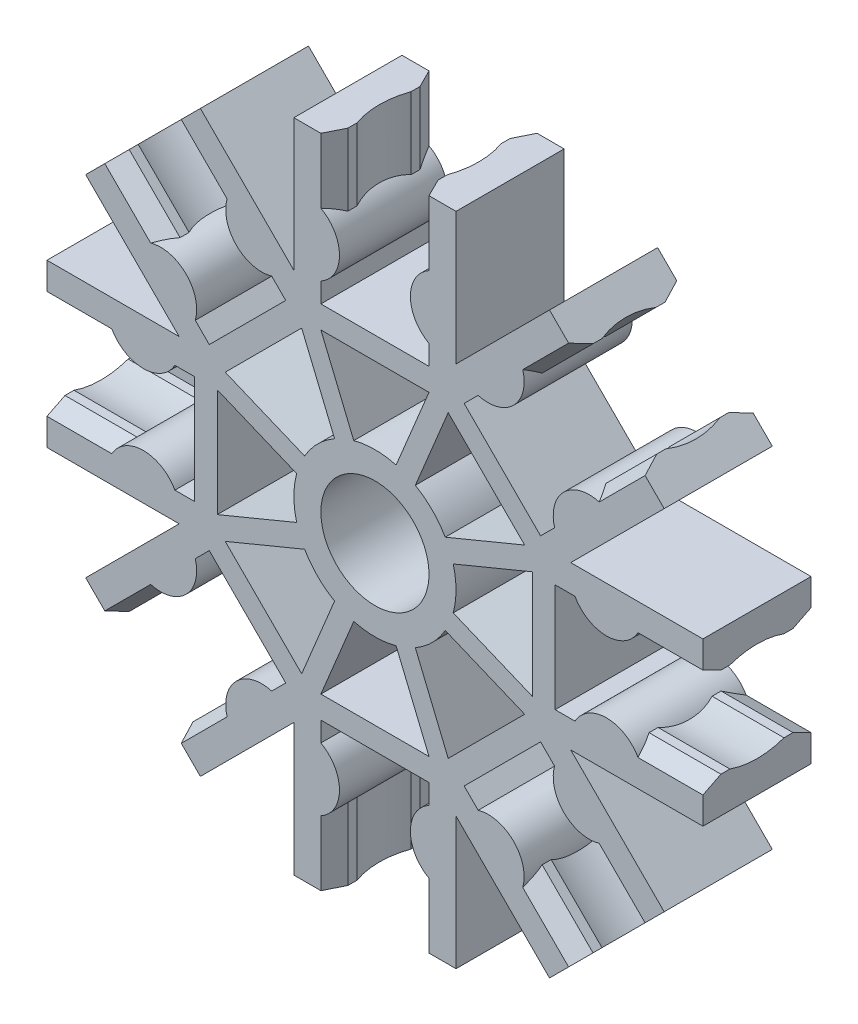
from build123d import *

# Parameters (mm, degrees)
EXTRUDE_1_DEPTH          = 6
EXTRUDE_2_REACH          = 25.907
PATTERN_CIRCULAR_1_COUNT = 8
SKETCH_4_R               = 3
CUT_EXTRUDE_1_DEPTH      = 27.42877236


with BuildPart() as part:
    # 草图1 → 凸台-拉伸1 (new body)
    with BuildSketch(Plane.XY):
        with BuildLine():
            Line((-4.5, 0), (-4.5, -18.2))
            Line((-4.5, -18.2), (-3, -18.2))
            Line((-3, -18.2), (-3, -14.6))
            ThreePointArc((-3, -14.6), (-1.968245837, -12.85), (-3, -11.1))
            Line((-3, -11.1), (-3, -10))
            Line((-3, -10), (3, -10))
            Line((3, -10), (3, -11.1))
            ThreePointArc((3, -11.1), (1.968245837, -12.85), (3, -14.6))
            Line((3, -14.6), (3, -18.2))
            Line((3, -18.2), (4.5, -18.2))
            Line((4.5, -18.2), (4.5, 0))
            ThreePointArc((4.5, 0), (0, 4.5), (-4.5, 0))
        make_face()
    extrude_1 = extrude(amount=EXTRUDE_1_DEPTH)

    # 草图3 → 凸台-拉伸2 (add, up to next)
    with BuildSketch(Plane.XZ.offset(18.2), mode=Mode.PRIVATE) as extrude_2_sk1:
        with BuildLine():
            Line((-3, 6), (-3, 0))
            Line((-3, 0), (-2.5, 1))
            Line((-2.5, 1), (-2.5, 1.5))
            ThreePointArc((-2.5, 1.5), (-2.757359313, 3), (-2.5, 4.5))
            Line((-2.5, 4.5), (-2.5, 5))
            Line((-2.5, 5), (-3, 6))
        make_face()
    extrude_2_tool1 = extrude(extrude_2_sk1.sketch, amount=-EXTRUDE_2_REACH, mode=Mode.PRIVATE) - part.part
    # 草图3 → 凸台-拉伸2 (add, up to next)
    with BuildSketch(Plane.XZ.offset(18.2), mode=Mode.PRIVATE) as extrude_2_sk2:
        with BuildLine():
            Line((3, 0), (2.5, 1))
            Line((2.5, 1), (2.5, 1.5))
            ThreePointArc((2.5, 1.5), (2.757359313, 3), (2.5, 4.5))
            Line((2.5, 4.5), (2.5, 5))
            Line((2.5, 5), (3, 6))
            Line((3, 6), (3, 0))
        make_face()
    extrude_2_tool2 = extrude(extrude_2_sk2.sketch, amount=-EXTRUDE_2_REACH, mode=Mode.PRIVATE) - part.part
    extrude_2_1 = extrude_2_tool1.solids().sort_by_distance((-2.809362, -18.2, 3))[0]
    add(extrude_2_1)
    extrude_2_2 = extrude_2_tool2.solids().sort_by_distance((2.809362, -18.2, 3))[0]
    add(extrude_2_2)
    extrude_2 = extrude_2_1 + extrude_2_2  # 凸台-拉伸2 as one shape, for the pattern or mirror that repeats it

    # 阵列(圆周)1: 凸台-拉伸1, 凸台-拉伸2 ×8 about axis
    pattern_circular_1_axis = Axis((0, 0, 0), (0, 0, 1))
    add([extrude_1.rotate(pattern_circular_1_axis, i * 360 / PATTERN_CIRCULAR_1_COUNT) for i in range(1, PATTERN_CIRCULAR_1_COUNT)])
    add([extrude_2.rotate(pattern_circular_1_axis, i * 360 / PATTERN_CIRCULAR_1_COUNT) for i in range(1, PATTERN_CIRCULAR_1_COUNT)])

    # 草图4 → 切除-拉伸1 (cut, through all)
    with BuildSketch(Plane(origin=(0, 0, 0), x_dir=(-1, 0, 0), z_dir=(0, 0, -1))):
        Circle(SKETCH_4_R)
        with BuildLine():
            Line((-3, -8.75), (3, -8.75))
            Line((3, -8.75), (1.174936357, -4.343906601))
            ThreePointArc((1.174936357, -4.343906601), (0, -4.5), (-1.174936357, -4.343906601))
            Line((-1.174936357, -4.343906601), (-3, -8.75))
        make_face()
        with BuildLine():
            Line((-8.308504679, -4.065863992), (-3.90241128, -2.240800349))
            ThreePointArc((-3.90241128, -2.240800349), (-3.181980515, -3.181980515), (-2.240800349, -3.90241128))
            Line((-2.240800349, -3.90241128), (-4.065863992, -8.308504679))
            Line((-4.065863992, -8.308504679), (-8.308504679, -4.065863992))
        make_face()
        with BuildLine():
            Line((-8.75, 3), (-4.343906601, 1.174936357))
            ThreePointArc((-4.343906601, 1.174936357), (-4.5, 0), (-4.343906601, -1.174936357))
            Line((-4.343906601, -1.174936357), (-8.75, -3))
            Line((-8.75, -3), (-8.75, 3))
        make_face()
        with BuildLine():
            Line((-4.065863992, 8.308504679), (-2.240800349, 3.90241128))
            ThreePointArc((-2.240800349, 3.90241128), (-3.181980515, 3.181980515), (-3.90241128, 2.240800349))
            Line((-3.90241128, 2.240800349), (-8.308504679, 4.065863992))
            Line((-8.308504679, 4.065863992), (-4.065863992, 8.308504679))
        make_face()
        with BuildLine():
            Line((3, 8.75), (1.174936357, 4.343906601))
            ThreePointArc((1.174936357, 4.343906601), (0, 4.5), (-1.174936357, 4.343906601))
            Line((-1.174936357, 4.343906601), (-3, 8.75))
            Line((-3, 8.75), (3, 8.75))
        make_face()
        with BuildLine():
            Line((8.308504679, 4.065863992), (3.90241128, 2.240800349))
            ThreePointArc((3.90241128, 2.240800349), (3.181980515, 3.181980515), (2.240800349, 3.90241128))
            Line((2.240800349, 3.90241128), (4.065863992, 8.308504679))
            Line((4.065863992, 8.308504679), (8.308504679, 4.065863992))
        make_face()
        with BuildLine():
            Line((8.75, -3), (4.343906601, -1.174936357))
            ThreePointArc((4.343906601, -1.174936357), (4.5, 0), (4.343906601, 1.174936357))
            Line((4.343906601, 1.174936357), (8.75, 3))
            Line((8.75, 3), (8.75, -3))
        make_face()
        with BuildLine():
            Line((4.065863992, -8.308504679), (2.240800349, -3.90241128))
            ThreePointArc((2.240800349, -3.90241128), (3.181980515, -3.181980515), (3.90241128, -2.240800349))
            Line((3.90241128, -2.240800349), (8.308504679, -4.065863992))
            Line((8.308504679, -4.065863992), (4.065863992, -8.308504679))
        make_face()
    extrude(amount=-CUT_EXTRUDE_1_DEPTH, mode=Mode.SUBTRACT)


solid = part.part
